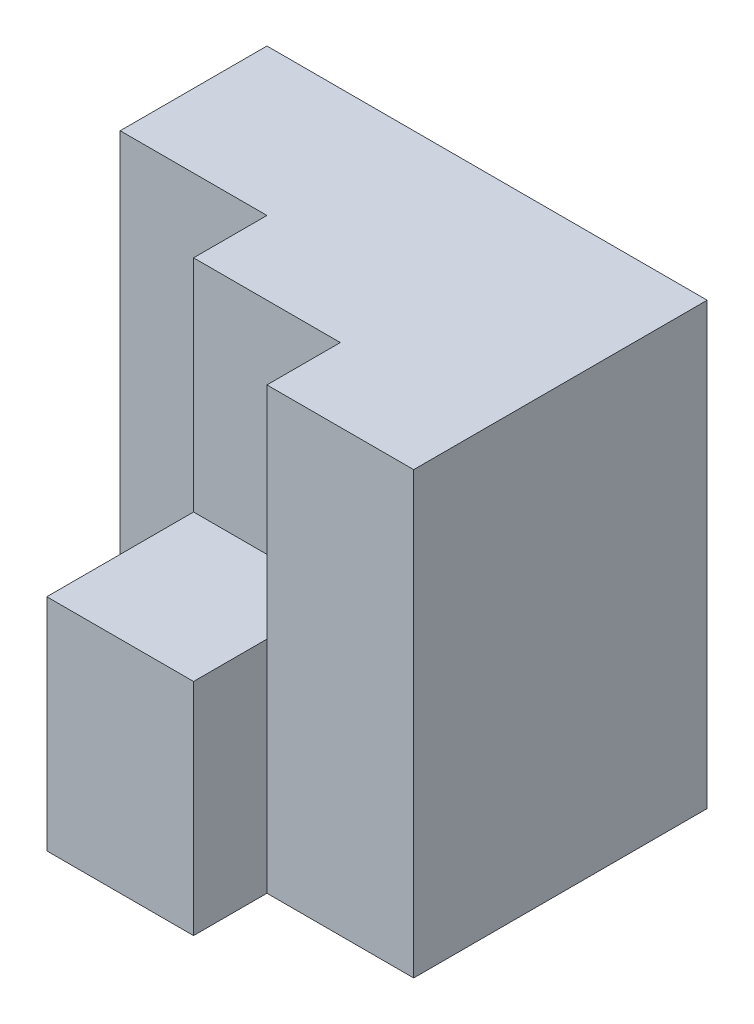
from build123d import *

# Parameters (mm, degrees)
SKETCH1_W           = 30
SKETCH1_H           = 30
BOSS_EXTRUDE1_DEPTH = 25
SKETCH2_W           = 10
SKETCH2_H           = 30
CUT_EXTRUDE1_DEPTH  = 5
SKETCH3_W           = 10
SKETCH3_H           = 30
CUT_EXTRUDE2_DEPTH  = 15
SKETCH4_W           = 10
SKETCH4_H           = 10
CUT_EXTRUDE3_DEPTH  = 15


with BuildPart() as part:
    # Sketch1 → Boss-Extrude1 (new body)
    with BuildSketch(Plane.XY):
        with Locations((15, 15)):
            Rectangle(SKETCH1_W, SKETCH1_H)
    extrude(amount=BOSS_EXTRUDE1_DEPTH)

    # Sketch2 → Cut-Extrude1 (cut)
    with BuildSketch(Plane.XY.offset(25)):
        with Locations((25, 15)):
            Rectangle(SKETCH2_W, SKETCH2_H)
    extrude(amount=-CUT_EXTRUDE1_DEPTH, mode=Mode.SUBTRACT)

    # Sketch3 → Cut-Extrude2 (cut)
    with BuildSketch(Plane.XY.offset(25)):
        with Locations((5, 15)):
            Rectangle(SKETCH3_W, SKETCH3_H)
    extrude(amount=-CUT_EXTRUDE2_DEPTH, mode=Mode.SUBTRACT)

    # Sketch4 → Cut-Extrude3 (cut)
    with BuildSketch(Plane(origin=(0, 30, 0), x_dir=(1, 0, 0), z_dir=(0, 1, 0))):
        with Locations((15, -20)):
            Rectangle(SKETCH4_W, SKETCH4_H)
    extrude(amount=-CUT_EXTRUDE3_DEPTH, mode=Mode.SUBTRACT)


solid = part.part
